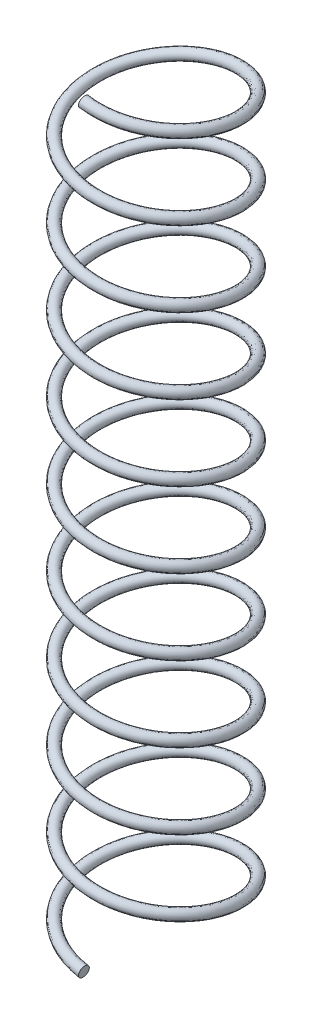
from build123d import *

# Parameters (mm, degrees)
SWEEP1_PITCH     = 7
SWEEP1_HEIGHT    = 70
SWEEP1_RADIUS    = 6.7
SWEEP1_PROFILE_R = 0.5


with BuildPart() as part:
    # Sweep1: sweep along a helix
    with BuildLine() as sweep1_path:
        Helix(SWEEP1_PITCH, SWEEP1_HEIGHT, SWEEP1_RADIUS, center=(0, 0, 0), direction=(0, 1, 0), lefthand=True)
    # Sweep1 profile (on start of the path) → Sweep1 (sweep)
    with BuildSketch(Plane(origin=(0, 0, 6.7), x_dir=(-0.164029087, -0.986455503, 0), z_dir=(-0.986455503, 0.164029087, 0))):
        Circle(SWEEP1_PROFILE_R)
    sweep(path=sweep1_path.line, is_frenet=True)


solid = part.part
